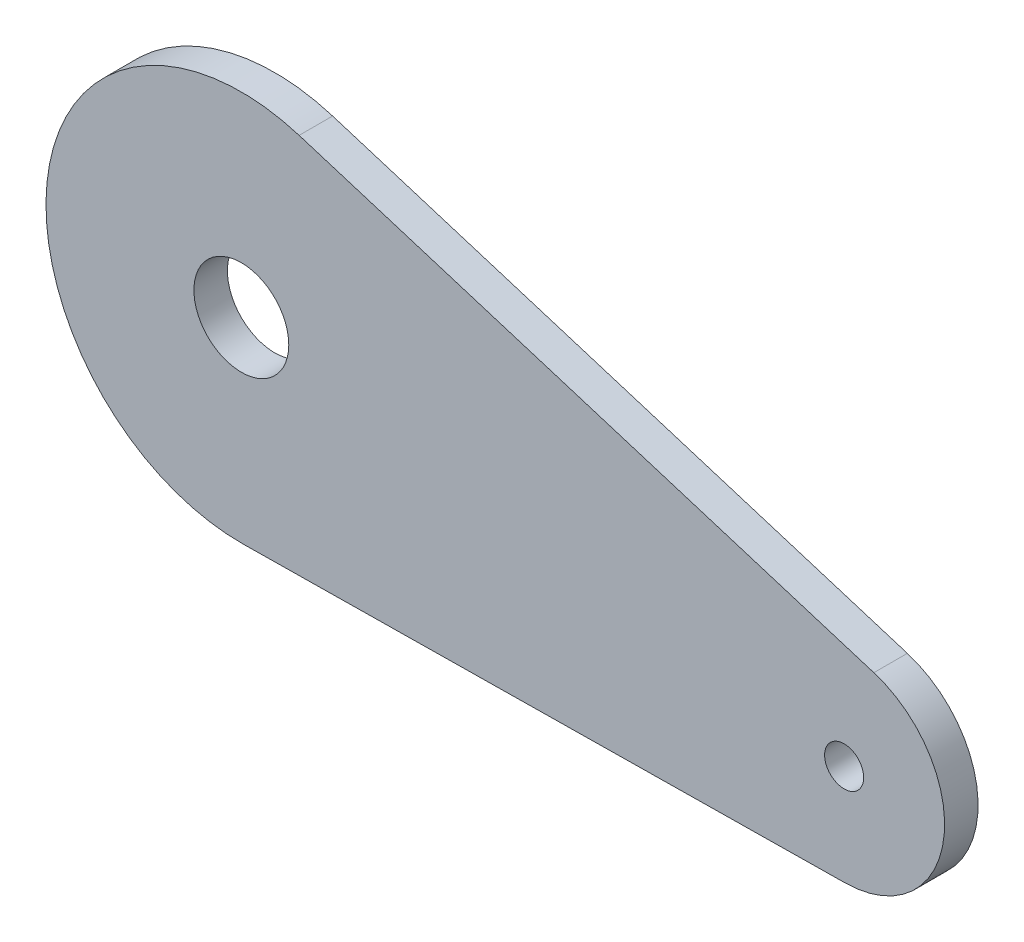
from build123d import *

# Parameters (mm, degrees)
SZKIC1_R                    = 4.25
SZKIC1_R_2                  = 1.75
DODANIE_WYCI_GNI_CIE1_DEPTH = 3


with BuildPart() as part:
    # Szkic1 → Dodanie-wyciągnięcie1 (new body)
    with BuildSketch(Plane.XY):
        with BuildLine():
            Line((-15.043613231, 74.296908208), (36.442141767, 58.354356054))
            ThreePointArc((36.442141767, 58.354356054), (42.687019735, 48.466740404), (33.892950846, 40.757797776))
            Line((33.892950846, 40.757797776), (-20.000373356, 40.081378222))
            ThreePointArc((-20.000373356, 40.081378222), (-37.539205041, 60.089011112), (-15.043613231, 74.296908208))
        make_face()
        with Locations((-20.22, 57.58)):
            Circle(SZKIC1_R, mode=Mode.SUBTRACT)
        with Locations((33.78, 49.757088976)):
            Circle(SZKIC1_R_2, mode=Mode.SUBTRACT)
    extrude(amount=DODANIE_WYCI_GNI_CIE1_DEPTH)


solid = part.part
